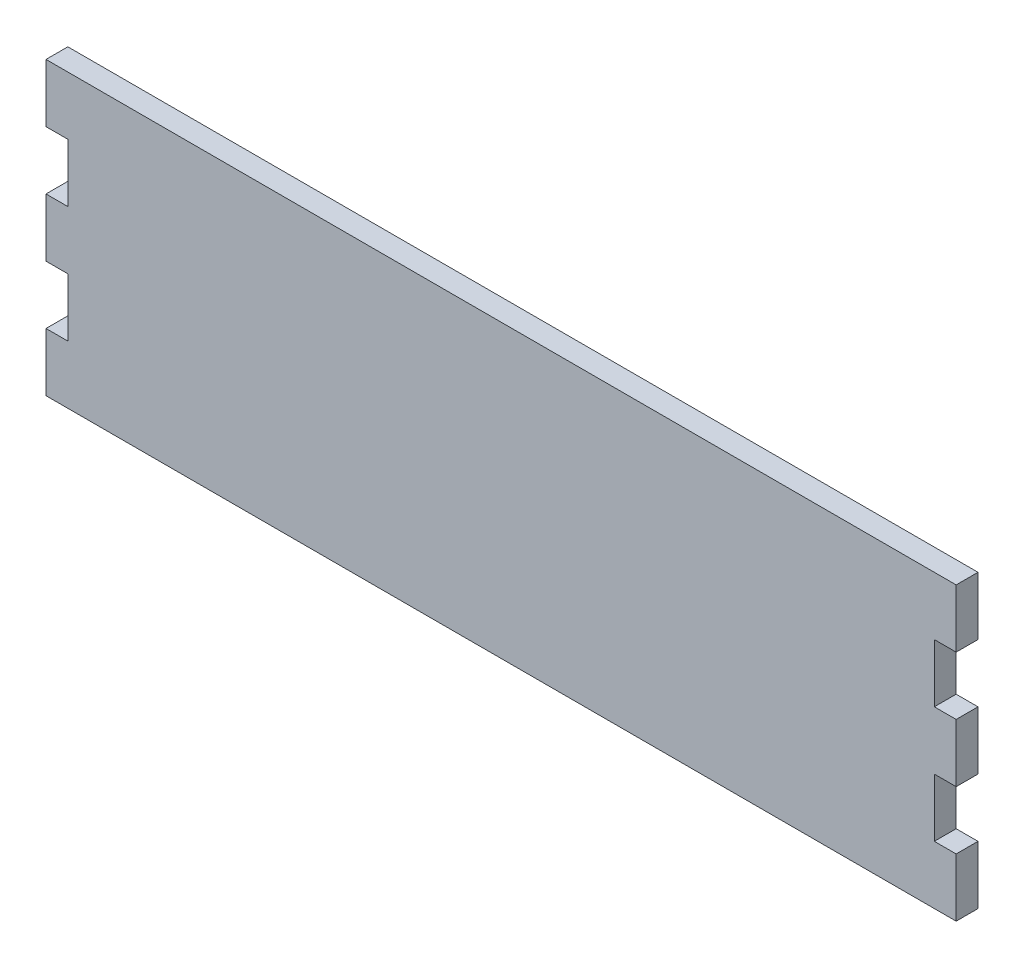
from build123d import *

# Parameters (mm, degrees)
CROQUIS1_W              = 250
CROQUIS1_H              = 80
SALIENTE_EXTRUIR1_DEPTH = 6
CROQUIS2_W              = 6
CROQUIS2_H              = 16
CORTAR_EXTRUIR1_DEPTH   = 6


with BuildPart() as part:
    # Croquis1 → Saliente-Extruir1 (new body)
    with BuildSketch(Plane.XY):
        Rectangle(CROQUIS1_W, CROQUIS1_H)
    extrude(amount=SALIENTE_EXTRUIR1_DEPTH)

    # Croquis2 → Cortar-Extruir1 (cut)
    with BuildSketch(Plane.XY.offset(6)):
        with Locations((-122, -16)):
            Rectangle(CROQUIS2_W, CROQUIS2_H)
        with Locations((-122, 16)):
            Rectangle(CROQUIS2_W, CROQUIS2_H)
        with Locations((122, -16)):
            Rectangle(CROQUIS2_W, CROQUIS2_H)
        with Locations((122, 16)):
            Rectangle(CROQUIS2_W, CROQUIS2_H)
    extrude(amount=-CORTAR_EXTRUIR1_DEPTH, mode=Mode.SUBTRACT)


solid = part.part
